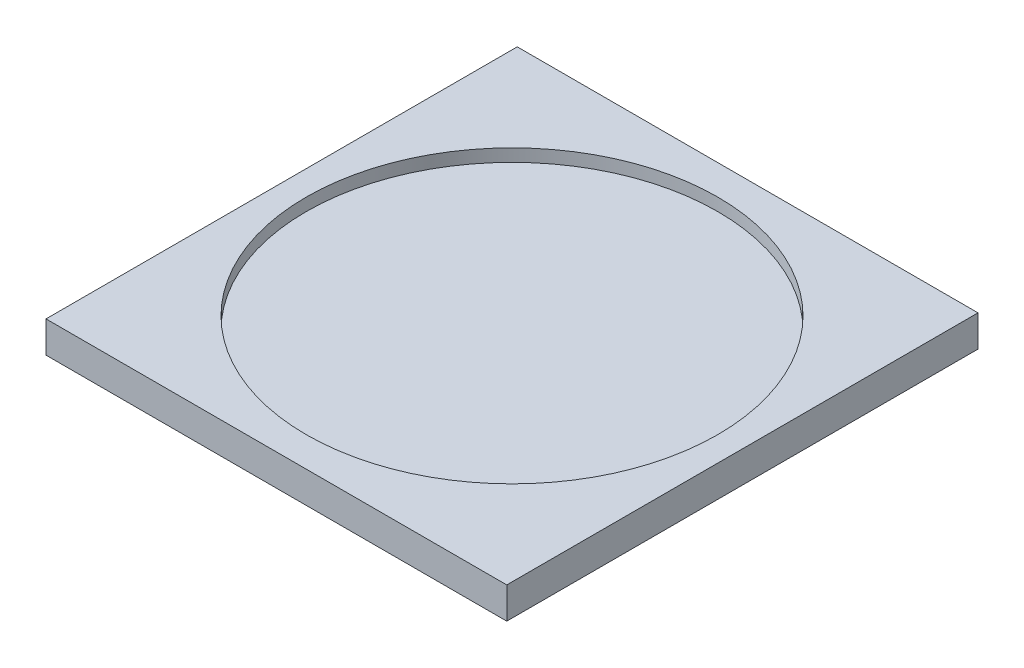
from build123d import *

# Parameters (mm, degrees)
SKETCH1_W           = 73.333333333
SKETCH1_H           = 75
BOSS_EXTRUDE1_DEPTH = 5
SKETCH2_R           = 32.75
CUT_EXTRUDE1_DEPTH  = 2


with BuildPart() as part:
    # Sketch1 → Boss-Extrude1 (new body)
    with BuildSketch(Plane(origin=(0, 0, 0), x_dir=(1, 0, 0), z_dir=(0, 1, 0))):
        with Locations((-36.666666666, 37.5)):
            Rectangle(SKETCH1_W, SKETCH1_H)
    extrude(amount=BOSS_EXTRUDE1_DEPTH)

    # Sketch2 → Cut-Extrude1 (cut)
    with BuildSketch(Plane(origin=(0, 5, 0), x_dir=(1, 0, 0), z_dir=(0, 1, 0))):
        with Locations((-36.666666667, 37.5)):
            Circle(SKETCH2_R)
    extrude(amount=-CUT_EXTRUDE1_DEPTH, mode=Mode.SUBTRACT)


solid = part.part
